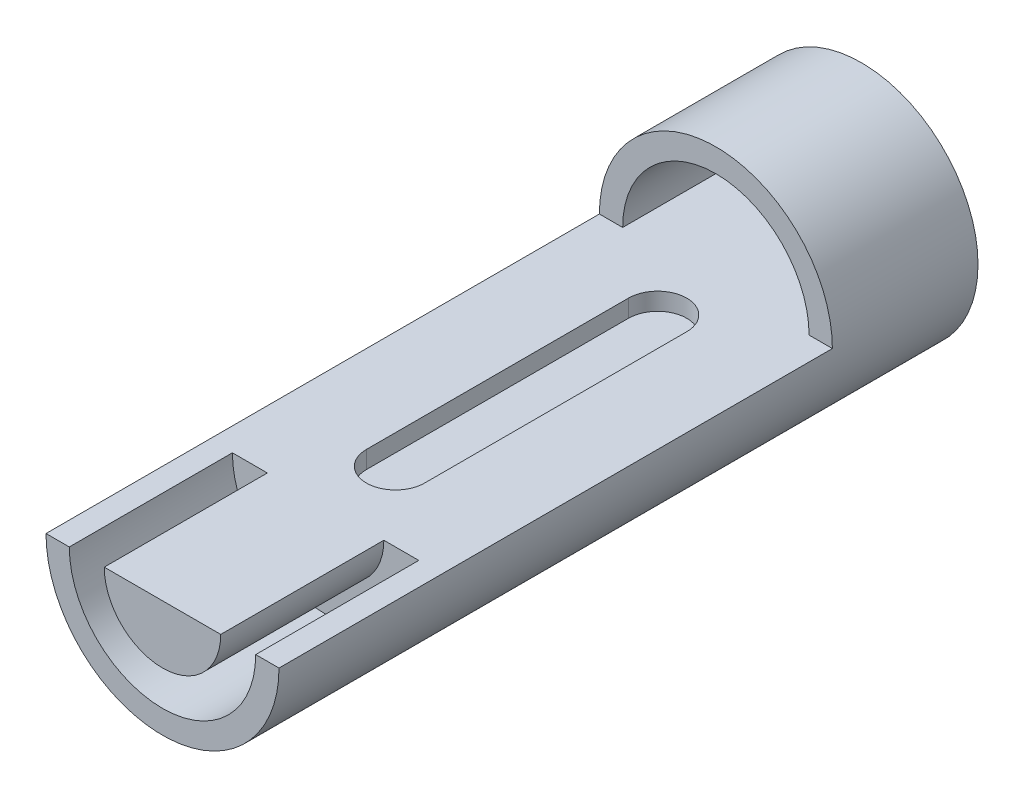
from build123d import *

# Parameters (mm, degrees)
SKETCH2_R           = 20
BOSS_EXTRUDE2_DEPTH = 120
SKETCH2_3_R         = 20
BOSS_EXTRUDE3_DEPTH = 120
CUT_EXTRUDE1_START  = -95
CUT_EXTRUDE1_DEPTH  = 95
CUT_EXTRUDE2_DEPTH  = 100.121138008
CUT_EXTRUDE3_DEPTH  = 28
CUT_EXTRUDE4_DEPTH  = 3


with BuildPart() as part:
    # Sketch2 → Boss-Extrude2 (new body)
    with BuildSketch(Plane.XY):
        Circle(SKETCH2_R)
    extrude(amount=BOSS_EXTRUDE2_DEPTH)

    # Sketch2_3 → Boss-Extrude3 (add)
    with BuildSketch(Plane.XY):
        Circle(SKETCH2_3_R)
    extrude(amount=BOSS_EXTRUDE3_DEPTH)

    # Sketch4 → Cut-Extrude1 (cut)
    with BuildSketch(Plane.XY.offset(120).offset(CUT_EXTRUDE1_START)):
        with BuildLine():
            Line((-20, 0), (20, 0))
            ThreePointArc((20, 0), (0, 20), (-20, 0))
        make_face()
    extrude(amount=CUT_EXTRUDE1_DEPTH, mode=Mode.SUBTRACT)

    # Sketch5 → Cut-Extrude2 (cut, through all)
    with BuildSketch(Plane.XY.offset(25)):
        with BuildLine():
            ThreePointArc((16, 0), (0, 16), (-16, 0))
            Line((-16, 0), (16, 0))
        make_face()
    extrude(amount=-CUT_EXTRUDE2_DEPTH, mode=Mode.SUBTRACT)

    # Sketch6 → Cut-Extrude3 (cut)
    with BuildSketch(Plane.XY.offset(120)):
        with BuildLine():
            Line((-10, 0), (-16, 0))
            ThreePointArc((-16, 0), (0, -16), (16, 0))
            Line((16, 0), (10, 0))
            ThreePointArc((10, 0), (0, -10), (-10, 0))
        make_face()
    extrude(amount=-CUT_EXTRUDE3_DEPTH, mode=Mode.SUBTRACT)

    # Sketch7 → Cut-Extrude4 (cut)
    with BuildSketch(Plane(origin=(0, 0, 0), x_dir=(1, 0, 0), z_dir=(0, 1, 0))):
        with BuildLine():
            ThreePointArc((5, -35), (0, -30), (-5, -35))
            Line((-5, -35), (-5, -80))
            ThreePointArc((-5, -80), (0, -85), (5, -80))
            Line((5, -80), (5, -35))
        make_face()
    extrude(amount=-CUT_EXTRUDE4_DEPTH, mode=Mode.SUBTRACT)


solid = part.part
